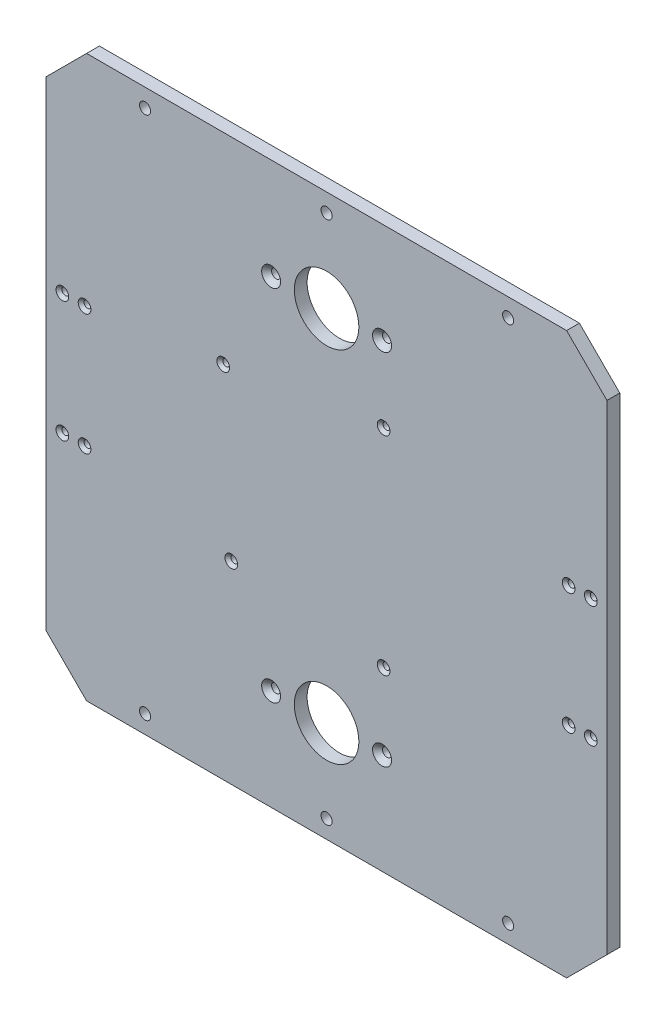
from build123d import *

# Parameters (mm, degrees)
SKETCH1_W                                       = 278
SKETCH1_H                                       = 278
BOSS_EXTRUDE1_DEPTH                             = 6.35
CHAMFER1_SIZE                                   = 20
SKETCH4_R                                       = 2.75
CUT_EXTRUDE2_DEPTH                              = 76.2
SKETCH8_R                                       = 16
CUT_EXTRUDE4_DEPTH                              = 105
CSK_FOR_M4_FLAT_HEAD_MACHINE_SCREW2_D           = 4.5
CSK_FOR_M4_FLAT_HEAD_MACHINE_SCREW2_CSINK_D     = 9.4
CSK_FOR_M4_FLAT_HEAD_MACHINE_SCREW2_CSINK_ANGLE = 90
CSK_FOR_M3_FLAT_HEAD_MACHINE_SCREW1_D           = 3.4
CSK_FOR_M3_FLAT_HEAD_MACHINE_SCREW1_CSINK_D     = 6.3
CSK_FOR_M3_FLAT_HEAD_MACHINE_SCREW1_CSINK_ANGLE = 90
CSK_FOR_M3_FLAT_HEAD_MACHINE_SCREW2_D           = 3.4
CSK_FOR_M3_FLAT_HEAD_MACHINE_SCREW2_CSINK_D     = 6.3
CSK_FOR_M3_FLAT_HEAD_MACHINE_SCREW2_CSINK_ANGLE = 90


with BuildPart() as part:
    # Sketch1 → Boss-Extrude1 (new body)
    with BuildSketch(Plane.XY):
        Rectangle(SKETCH1_W, SKETCH1_H)
    extrude(amount=BOSS_EXTRUDE1_DEPTH)

    # Chamfer1
    chamfer1_edges = [part.edges().sort_by_distance(p)[0] for p in [
        (-139, 139, 3.175),
        (139, 139, 3.175),
        (139, -139, 3.175),
        (-139, -139, 3.175),
    ]]
    chamfer(chamfer1_edges, length=CHAMFER1_SIZE)

    # Sketch4 → Cut-Extrude2 (cut)
    with BuildSketch(Plane.XY.offset(6.35)):
        with Locations((-90, 130)):
            Circle(SKETCH4_R)
        with Locations((0, 130)):
            Circle(SKETCH4_R)
        with Locations((90, 130)):
            Circle(SKETCH4_R)
        with Locations((90, -130)):
            Circle(SKETCH4_R)
        with Locations((0, -130)):
            Circle(SKETCH4_R)
        with Locations((-90, -130)):
            Circle(SKETCH4_R)
    extrude(amount=-CUT_EXTRUDE2_DEPTH, mode=Mode.SUBTRACT)

    # Sketch8 → Cut-Extrude4 (cut)
    with BuildSketch(Plane.XY.offset(6.35)):
        with Locations((0, 89)):
            Circle(SKETCH8_R)
        with Locations((0, -89)):
            Circle(SKETCH8_R)
    extrude(amount=-CUT_EXTRUDE4_DEPTH, mode=Mode.SUBTRACT)

    # CSK for M4 Flat Head Machine Screw2 (through all)
    with Locations(Plane.XY.offset(6.35)):
        with Locations((-27.5, 89), (27.5, 89), (27.5, -89), (-27.5, -89)):
            CounterSinkHole(CSK_FOR_M4_FLAT_HEAD_MACHINE_SCREW2_D / 2, CSK_FOR_M4_FLAT_HEAD_MACHINE_SCREW2_CSINK_D / 2, counter_sink_angle=CSK_FOR_M4_FLAT_HEAD_MACHINE_SCREW2_CSINK_ANGLE)

    # CSK for M3 Flat Head Machine Screw1 (through all)
    with Locations(Plane.XY.offset(6.35)):
        with Locations((-131, 30), (-120, 30), (-120, -30), (-131, -30), (131, -30), (120, -30), (120, 30), (131, 30)):
            CounterSinkHole(CSK_FOR_M3_FLAT_HEAD_MACHINE_SCREW1_D / 2, CSK_FOR_M3_FLAT_HEAD_MACHINE_SCREW1_CSINK_D / 2, counter_sink_angle=CSK_FOR_M3_FLAT_HEAD_MACHINE_SCREW1_CSINK_ANGLE)

    # CSK for M3 Flat Head Machine Screw2 (through all)
    with Locations(Plane.XY.offset(6.35)):
        with Locations((-47.23657748, -43.137455791), (-51.23657748, 39.362544209), (28.26342252, 51.862544209), (28.26342252, -51.137455791)):
            CounterSinkHole(CSK_FOR_M3_FLAT_HEAD_MACHINE_SCREW2_D / 2, CSK_FOR_M3_FLAT_HEAD_MACHINE_SCREW2_CSINK_D / 2, counter_sink_angle=CSK_FOR_M3_FLAT_HEAD_MACHINE_SCREW2_CSINK_ANGLE)


solid = part.part
